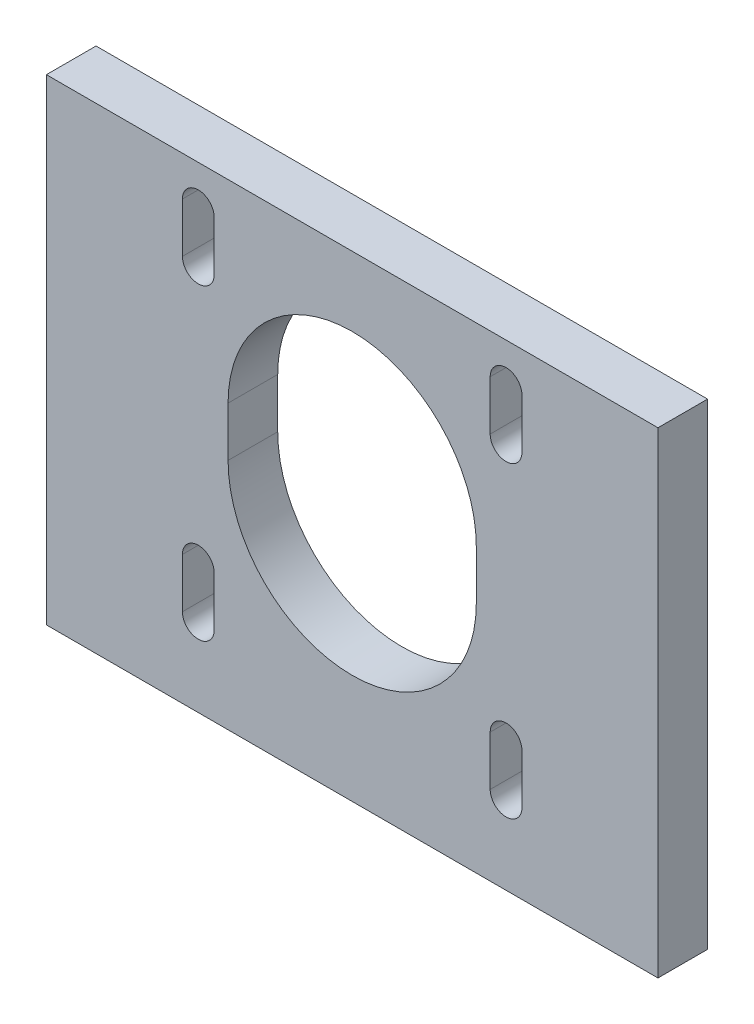
from build123d import *

# Parameters (mm, degrees)
SKETCH1_W           = 61.6
SKETCH1_H           = 42
BOSS_EXTRUDE1_DEPTH = 5
CUT_EXTRUDE1_DEPTH  = 5
SKETCH3_W           = 61.6
SKETCH3_H           = 6
BOSS_EXTRUDE2_DEPTH = 5


with BuildPart() as part:
    # Sketch1 → Boss-Extrude1 (new body)
    with BuildSketch(Plane.XY):
        with Locations((0, 31)):
            Rectangle(SKETCH1_W, SKETCH1_H)
    extrude(amount=BOSS_EXTRUDE1_DEPTH)

    # Sketch2 → Cut-Extrude1 (cut)
    with BuildSketch(Plane.XY.offset(5)):
        with BuildLine():
            Line((-12.5, 27.5), (-12.5, 32.5))
            ThreePointArc((-12.5, 32.5), (0, 45), (12.5, 32.5))
            Line((12.5, 32.5), (12.5, 27.5))
            ThreePointArc((12.5, 27.5), (0, 15), (-12.5, 27.5))
        make_face()
        with BuildLine():
            Line((-17.1, 45.5), (-17.1, 48))
            ThreePointArc((-17.1, 48), (-15.5, 49.6), (-13.9, 48))
            Line((-13.9, 48), (-13.9, 45.5))
            Line((-13.9, 45.5), (-13.9, 43))
            ThreePointArc((-13.9, 43), (-15.5, 41.4), (-17.1, 43))
            Line((-17.1, 43), (-17.1, 45.5))
        make_face()
        with BuildLine():
            Line((-17.1, 14.5), (-17.1, 12))
            ThreePointArc((-17.1, 12), (-15.5, 10.4), (-13.9, 12))
            Line((-13.9, 12), (-13.9, 14.5))
            Line((-13.9, 14.5), (-13.9, 17))
            ThreePointArc((-13.9, 17), (-15.5, 18.6), (-17.1, 17))
            Line((-17.1, 17), (-17.1, 14.5))
        make_face()
        with BuildLine():
            Line((13.9, 12), (13.9, 14.5))
            Line((13.9, 14.5), (13.9, 17))
            ThreePointArc((13.9, 17), (15.5, 18.6), (17.1, 17))
            Line((17.1, 17), (17.1, 14.5))
            Line((17.1, 14.5), (17.1, 12))
            ThreePointArc((17.1, 12), (15.5, 10.4), (13.9, 12))
        make_face()
        with BuildLine():
            Line((17.1, 45.5), (17.1, 48))
            ThreePointArc((17.1, 48), (15.5, 49.6), (13.9, 48))
            Line((13.9, 48), (13.9, 45.5))
            Line((13.9, 45.5), (13.9, 43))
            ThreePointArc((13.9, 43), (15.5, 41.4), (17.1, 43))
            Line((17.1, 43), (17.1, 45.5))
        make_face()
    extrude(amount=-CUT_EXTRUDE1_DEPTH, mode=Mode.SUBTRACT)

    # Sketch3 → Boss-Extrude2 (add)
    with BuildSketch(Plane.XY.offset(5)):
        with Locations((0, 7)):
            Rectangle(SKETCH3_W, SKETCH3_H)
    extrude(amount=-BOSS_EXTRUDE2_DEPTH)


solid = part.part
